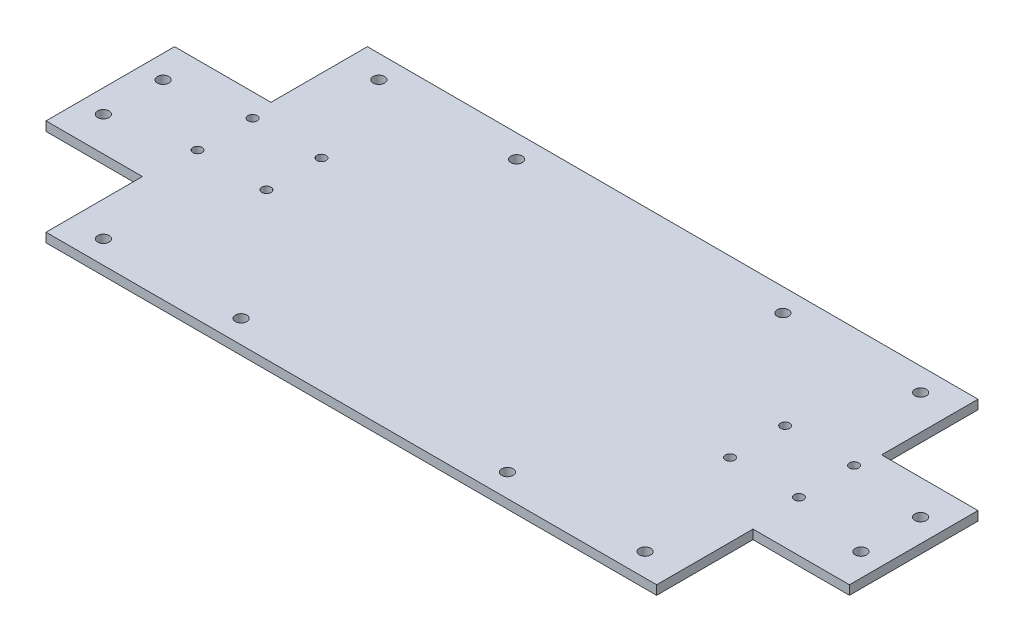
from build123d import *

# Parameters (mm, degrees)
SKETCH1_W           = 350
SKETCH1_H           = 140
BOSS_EXTRUDE1_DEPTH = 4
SKETCH2_R           = 2.5
SKETCH2_W           = 42
SKETCH2_H           = 42
CUT_EXTRUDE1_DEPTH  = 5
SKETCH3_R           = 2
CUT_EXTRUDE2_DEPTH  = 10


with BuildPart() as part:
    # Sketch1 → Boss-Extrude1 (new body)
    with BuildSketch(Plane(origin=(0, 0, 0), x_dir=(1, 0, 0), z_dir=(0, 1, 0))):
        Rectangle(SKETCH1_W, SKETCH1_H)
    extrude(amount=BOSS_EXTRUDE1_DEPTH)

    # Sketch2 → Cut-Extrude1 (cut, through all)
    with BuildSketch(Plane(origin=(0, 4, 0), x_dir=(1, 0, 0), z_dir=(0, 1, 0))):
        with Locations((-165, 13)):
            Circle(SKETCH2_R)
        with Locations((-165, -13)):
            Circle(SKETCH2_R)
        with Locations((165, -13)):
            Circle(SKETCH2_R)
        with Locations((165, 13)):
            Circle(SKETCH2_R)
        with Locations((-118, 60)):
            Circle(SKETCH2_R)
        with Locations((-58, 60)):
            Circle(SKETCH2_R)
        with Locations((58, 60)):
            Circle(SKETCH2_R)
        with Locations((118, 60)):
            Circle(SKETCH2_R)
        with Locations((118, -60)):
            Circle(SKETCH2_R)
        with Locations((58, -60)):
            Circle(SKETCH2_R)
        with Locations((-58, -60)):
            Circle(SKETCH2_R)
        with Locations((-118, -60)):
            Circle(SKETCH2_R)
        with Locations((-154, -49)):
            Rectangle(SKETCH2_W, SKETCH2_H)
        with Locations((154, -49)):
            Rectangle(SKETCH2_W, SKETCH2_H)
        with Locations((154, 49)):
            Rectangle(SKETCH2_W, SKETCH2_H)
        with Locations((-154, 49)):
            Rectangle(SKETCH2_W, SKETCH2_H)
    extrude(amount=-CUT_EXTRUDE1_DEPTH, mode=Mode.SUBTRACT)

    # Sketch3 → Cut-Extrude2 (cut)
    with BuildSketch(Plane(origin=(0, 4, 0), x_dir=(1, 0, 0), z_dir=(0, 1, 0))):
        with Locations((-131, -6)):
            Circle(SKETCH3_R)
        with Locations((-101, -6)):
            Circle(SKETCH3_R)
        with Locations((-101, 18)):
            Circle(SKETCH3_R)
        with Locations((101, -6)):
            Circle(SKETCH3_R)
        with Locations((-131, 18)):
            Circle(SKETCH3_R)
        with Locations((101, 18)):
            Circle(SKETCH3_R)
        with Locations((131, 18)):
            Circle(SKETCH3_R)
        with Locations((131, -6)):
            Circle(SKETCH3_R)
    extrude(amount=-CUT_EXTRUDE2_DEPTH, mode=Mode.SUBTRACT)


solid = part.part
